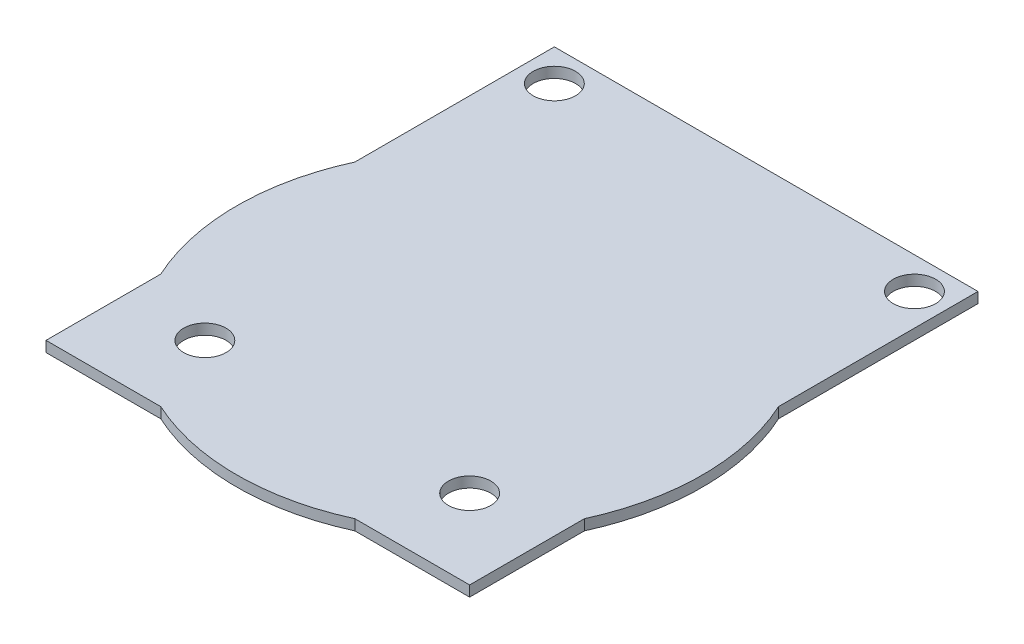
from build123d import *

# Parameters (mm, degrees)
SKETCH1_R           = 2
BOSS_EXTRUDE1_DEPTH = 1


with BuildPart() as part:
    # Sketch1 → Boss-Extrude1 (new body)
    with BuildSketch(Plane(origin=(0, 0, 0), x_dir=(1, 0, 0), z_dir=(0, 1, 0))):
        with BuildLine():
            Line((12.20211229, -1.662478542), (12.20211229, 17.172370068))
            Line((12.20211229, 17.172370068), (-27.79788771, 17.172370068))
            Line((-27.79788771, 17.172370068), (-27.79788771, -1.662478542))
            ThreePointArc((-27.79788771, -1.662478542), (-29.79788771, -10.827629932), (-27.79788771, -19.992781322))
            Line((-27.79788771, -19.992781322), (-27.79788771, -30.827629932))
            Line((-27.79788771, -30.827629932), (-16.9630391, -30.827629932))
            ThreePointArc((-16.9630391, -30.827629932), (-7.79788771, -32.827629932), (1.36726368, -30.827629932))
            Line((1.36726368, -30.827629932), (12.20211229, -30.827629932))
            Line((12.20211229, -30.827629932), (12.20211229, -19.992781322))
            ThreePointArc((12.20211229, -19.992781322), (14.20211229, -10.827629932), (12.20211229, -1.662478542))
        make_face()
        with Locations((-20.29788771, -23.327629932)):
            Circle(SKETCH1_R, mode=Mode.SUBTRACT)
        with Locations((4.70211229, -23.327629932)):
            Circle(SKETCH1_R, mode=Mode.SUBTRACT)
        with Locations((-24.79788771, 14.172370068)):
            Circle(SKETCH1_R, mode=Mode.SUBTRACT)
        with Locations((9.20211229, 14.172370068)):
            Circle(SKETCH1_R, mode=Mode.SUBTRACT)
    extrude(amount=BOSS_EXTRUDE1_DEPTH)


solid = part.part
